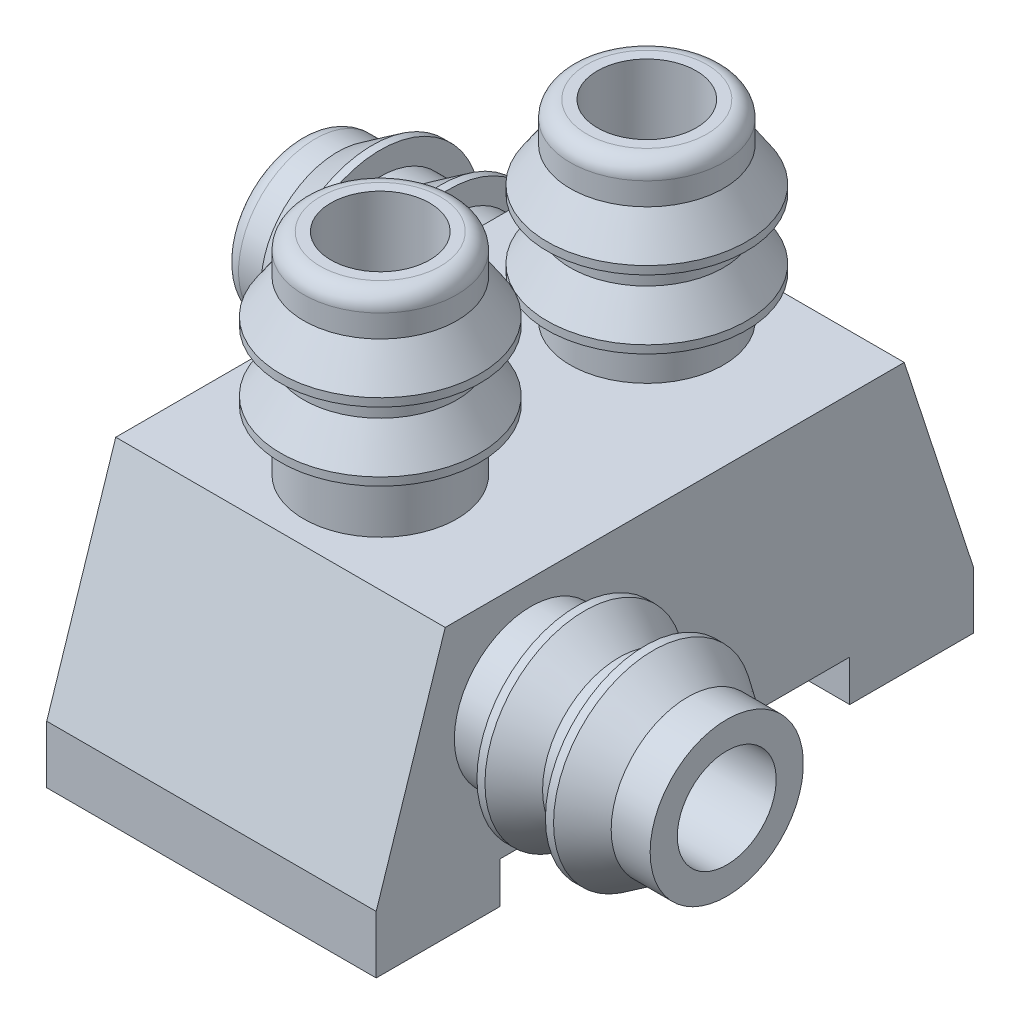
from build123d import *

# Parameters (mm, degrees)
BOSS_EXTRUDE2_DEPTH = 4
SKETCH10_R          = 0.6
CUT_EXTRUDE3_DEPTH  = 2
SKETCH14_R          = 0.6
CUT_EXTRUDE5_DEPTH  = 2.6
SKETCH15_R          = 0.6
CUT_EXTRUDE6_DEPTH  = 3
FILLET3_R           = 0.2


with BuildPart() as part:
    # Sketch3 → Boss-Extrude2 (new body)
    with BuildSketch(Plane(origin=(0, 0, 0), x_dir=(0, 0, -1), z_dir=(1, 0, 0))):
        Polygon((-20.123053839, -5.770870406), (-14.550172907, -5.770870406), (-13.712271186, -8.337564915), (-13.712271186, -9.037564915), (-15.212271186, -9.037564915), (-15.212271186, -8.537564915), (-19.46095556, -8.537564915), (-19.46095556, -9.037564915), (-20.96095556, -9.037564915), (-20.96095556, -8.337564915), align=None)
    extrude(amount=BOSS_EXTRUDE2_DEPTH)

    # Sketch5 → Revolve2 (revolve)
    with BuildSketch(Plane(origin=(2, 0, 0), x_dir=(0, 0, -1), z_dir=(1, 0, 0)), mode=Mode.PRIVATE) as revolve2_sk:
        Polygon((-19.841868378, -5.839481614), (-19.511618443, -5.839481614), (-19.511618443, -3.21350004), (-19.841868378, -3.21350004), (-19.841868378, -3.686663005), (-20.121551797, -4.10664197), (-20.121551797, -4.205331029), (-19.841868378, -4.205331029), (-19.841868378, -4.519502648), (-20.121551797, -4.939481613), (-20.121551797, -5.036674624), (-19.841868378, -5.036674624), align=None)
    revolve(revolve2_sk.sketch.rotate(Axis((2, -5.639481613, 18.911618443), (0, 1, 0)), 180), axis=Axis((2, -5.639481613, 18.911618443), (0, 1, 0)))

    # Sketch6 → Revolve3 (revolve)
    with BuildSketch(Plane(origin=(2, 0, 0), x_dir=(0, 0, -1), z_dir=(1, 0, 0)), mode=Mode.PRIVATE) as revolve3_sk:
        Polygon((-16.605788013, -6.065180205), (-16.275538078, -6.065180205), (-16.275538078, -3.44200562), (-16.605788013, -3.44200562), (-16.605788013, -3.915168585), (-16.885471432, -4.335147551), (-16.885471432, -4.433836609), (-16.605788013, -4.433836609), (-16.605788013, -4.748008228), (-16.885471432, -5.167987194), (-16.885471432, -5.265180205), (-16.605788013, -5.265180205), align=None)
    revolve(revolve3_sk.sketch.rotate(Axis((2, -6.067987194, 15.675538078), (0, 1, 0)), 180), axis=Axis((2, -6.067987194, 15.675538078), (0, 1, 0)))

    # Sketch10 → Cut-Extrude3 (cut)
    with BuildSketch(Plane(origin=(0, -5.770870406, 0), x_dir=(1, 0, 0), z_dir=(0, 1, 0))):
        with Locations(Location((2, -18.911618443, 0), (0, 0, 90))):
            Circle(SKETCH10_R)
        with Locations(Location((2, -15.675538078, 0), (0, 0, 90))):
            Circle(SKETCH10_R)
    extrude(amount=-CUT_EXTRUDE3_DEPTH, mode=Mode.SUBTRACT)

    # Sketch12 → Revolve5 (revolve)
    with BuildSketch(Plane(origin=(0, -7, 0), x_dir=(1, 0, 0), z_dir=(0, 1, 0)), mode=Mode.PRIVATE) as revolve5_sk:
        Polygon((0, -16.405788013), (0, -16.075538078), (-2.425981573, -16.075538078), (-2.425981573, -16.405788013), (-1.952818609, -16.405788013), (-1.532839643, -16.685471432), (-1.434150585, -16.685471432), (-1.434150585, -16.405788013), (-1.119978965, -16.405788013), (-0.7, -16.685471432), (-0.602806989, -16.685471432), (-0.602806989, -16.405788013), align=None)
    revolve(revolve5_sk.sketch.rotate(Axis((0, -7, 15.475538078), (-1, 0, 0)), 180), axis=Axis((0, -7, 15.475538078), (-1, 0, 0)))

    # Sketch13 → Revolve6 (revolve)
    with BuildSketch(Plane(origin=(0, -7, 0), x_dir=(1, 0, 0), z_dir=(0, 1, 0))):
        Polygon((4.553932823, -20.292068689), (4.553932823, -20.012385269), (3.951125834, -20.012385269), (3.951125834, -19.682135334), (6.377107408, -19.682135334), (6.377107408, -20.012385269), (5.903944443, -20.012385269), (5.483965478, -20.292068689), (5.385276419, -20.292068689), (5.385276419, -20.012385269), (5.0711048, -20.012385269), (4.651125834, -20.292068689), align=None)
    revolve(axis=Axis((3.951125834, -7, 19.082135334), (1, 0, 0)))

    # Sketch14 → Cut-Extrude5 (cut)
    with BuildSketch(Plane.ZY):
        with Locations(Location((15.475538078, -7, 0), (0, 0, 180))):
            Circle(SKETCH14_R)
    extrude(amount=-CUT_EXTRUDE5_DEPTH, mode=Mode.SUBTRACT)

    # Sketch15 → Cut-Extrude6 (cut)
    with BuildSketch(Plane(origin=(4, 0, 0), x_dir=(0, 0, -1), z_dir=(1, 0, 0))):
        with Locations(Location((-19.082135334, -7, 0), (0, 0, 180))):
            Circle(SKETCH15_R)
    extrude(amount=-CUT_EXTRUDE6_DEPTH, mode=Mode.SUBTRACT)

    # Fillet3
    fillet3_edges = [part.edges().sort_by_distance(p)[0] for p in [
        (2, -3.21350004, 19.841868378),
        (2, -3.44200562, 16.605788013),
        (-2.425981573, -7, 16.405788013),
    ]]
    fillet(fillet3_edges, radius=FILLET3_R)


solid = part.part
